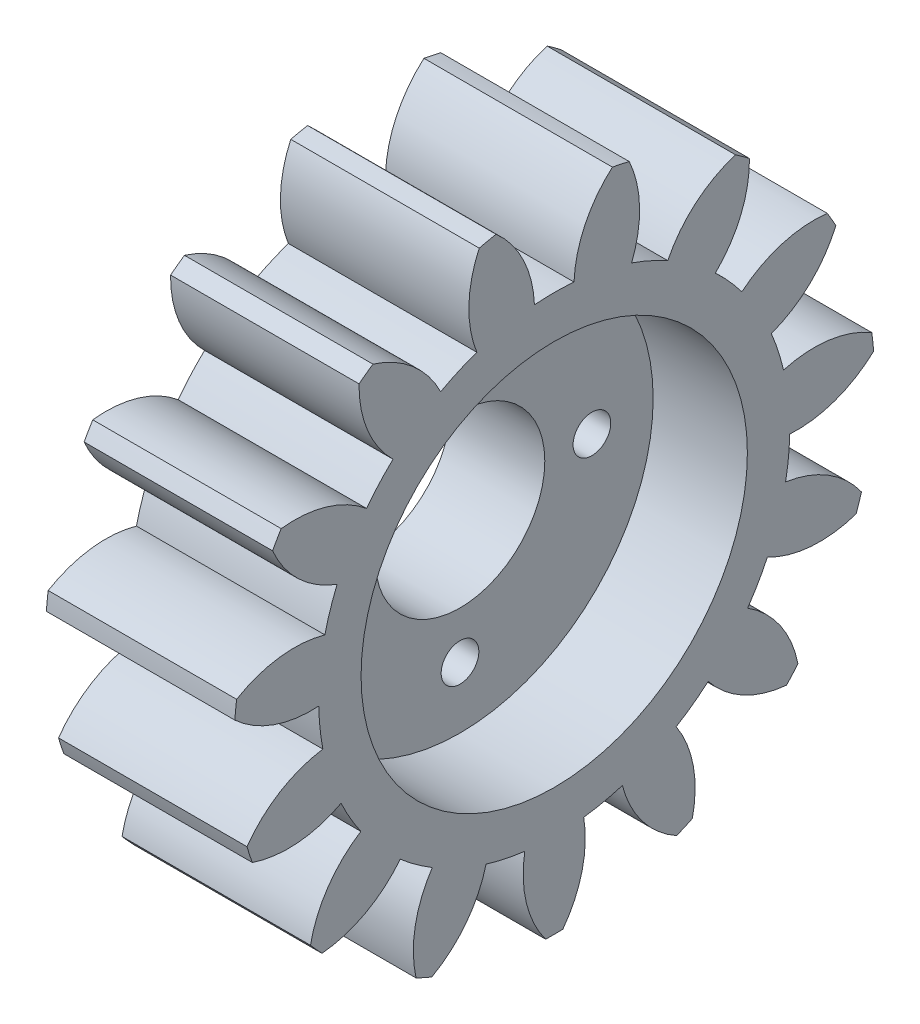
from build123d import *

# Parameters (mm, degrees)
BASPROSKE_W         = 10
BASPROSKE_H         = 17
TOOTHCUT_DEPTH      = 27.038433133
TEETHCUTS_COUNT     = 15
BORSKE_R            = 10.25
BORE_DEPTH          = 10
SKETCH1_R           = 10.25
SKETCH1_R_2         = 1
SKETCH1_R_3         = 4.5
BOSS_EXTRUDE1_DEPTH = 5


with BuildPart() as part:
    # BasProSke → Base-Revolve (revolve)
    with BuildSketch(Plane(origin=(0, 0, 0), x_dir=(1, 0, 0), z_dir=(0, 1, 0)), mode=Mode.PRIVATE) as base_revolve_sk:
        with Locations((5, 8.5)):
            Rectangle(BASPROSKE_W, BASPROSKE_H)
    revolve(base_revolve_sk.sketch.rotate(Axis((-10, 0, 0), (1, 0, 0)), 180), axis=Axis((-10, 0, 0), (1, 0, 0)))

    # TooCutSke → ToothCut (cut, through all)
    with BuildSketch(Plane(origin=(0, 0, 0), x_dir=(0, 0, -1), z_dir=(1, 0, 0))):
        with BuildLine():
            ThreePointArc((1.050056448, 12.454813626), (0, 12.499), (-1.050056448, 12.454813626))
            ThreePointArc((-1.050056448, 12.454813626), (-1.638118106, 14.809604533), (-3.110934279, 16.73876737))
            ThreePointArc((-3.110934279, 16.73876737), (0, 17.0254), (3.110934279, 16.73876737))
            ThreePointArc((3.110934279, 16.73876737), (1.638118106, 14.809604533), (1.050056448, 12.454813626))
        make_face()
    toothcut = extrude(amount=TOOTHCUT_DEPTH, mode=Mode.SUBTRACT)

    # TeethCuts: ToothCut ×15 about axis
    teethcuts_axis = Axis((0, 0, 0), (1, 0, 0))
    for i in range(1, TEETHCUTS_COUNT):
        add(toothcut.rotate(teethcuts_axis, i * 360 / TEETHCUTS_COUNT), mode=Mode.SUBTRACT)

    # BorSke → Bore (cut, symmetric)
    with BuildSketch(Plane(origin=(0, 0, 0), x_dir=(0, 0, -1), z_dir=(1, 0, 0))):
        with Locations(Location((0, 0, 0), (0, 0, 180))):
            Circle(BORSKE_R)
    extrude(amount=BORE_DEPTH, both=True, mode=Mode.SUBTRACT)

    # Sketch1 → Boss-Extrude1 (add)
    with BuildSketch(Plane(origin=(0, 0, 0), x_dir=(0, 0, -1), z_dir=(1, 0, 0))):
        with Locations(Location((0, 0, 0), (0, 0, 180))):
            Circle(SKETCH1_R)
        with Locations((7, 0)):
            Circle(SKETCH1_R_2, mode=Mode.SUBTRACT)
        with Locations((-7, 0)):
            Circle(SKETCH1_R_2, mode=Mode.SUBTRACT)
        with Locations((0, 7)):
            Circle(SKETCH1_R_2, mode=Mode.SUBTRACT)
        with Locations((0, -7)):
            Circle(SKETCH1_R_2, mode=Mode.SUBTRACT)
        Circle(SKETCH1_R_3, mode=Mode.SUBTRACT)
    extrude(amount=BOSS_EXTRUDE1_DEPTH)


solid = part.part
